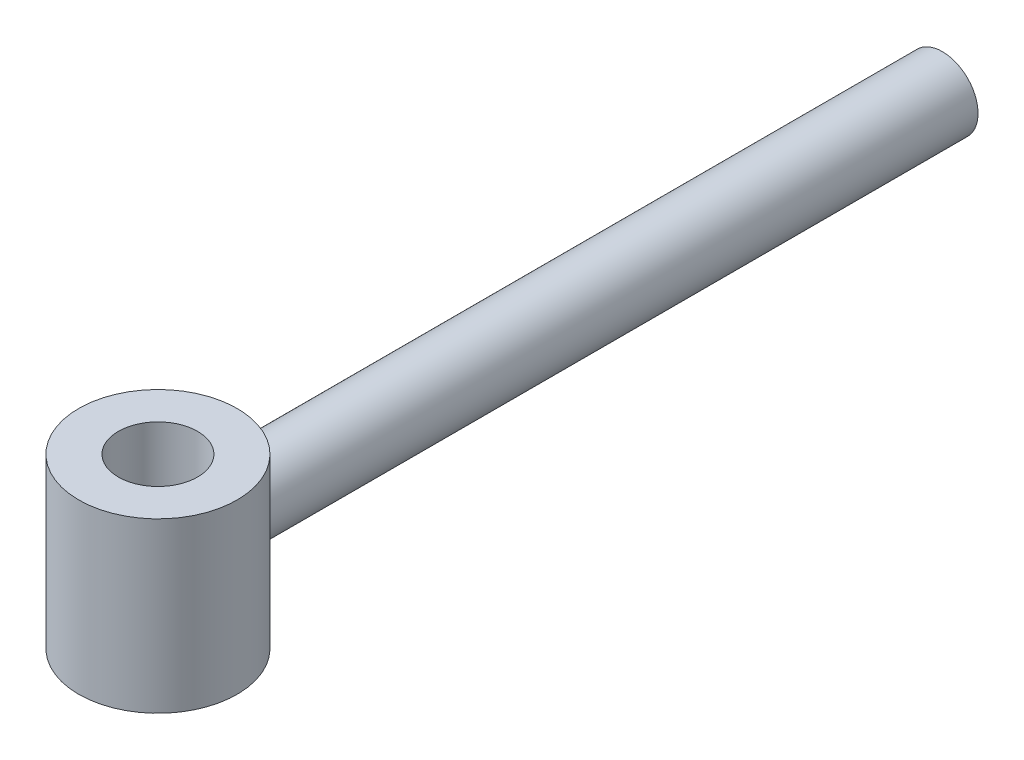
from build123d import *

# Parameters (mm, degrees)
SKETCH1_R                = 40
SKETCH1_R_2              = 20
BOSS_EXTRUDE1_DEPTH      = 80
BOSS_EXTRUDE1_DEPTH_BACK = 5
SKETCH2_R                = 18
BOSS_EXTRUDE2_DEPTH      = 356
BOSS_EXTRUDE2_DEPTH_BACK = 13


with BuildPart() as part:
    # Sketch1 → Boss-Extrude1 (new body, two sides)
    with BuildSketch(Plane(origin=(0, 0, 0), x_dir=(1, 0, 0), z_dir=(0, 1, 0))) as boss_extrude1_sk:
        Circle(SKETCH1_R)
        Circle(SKETCH1_R_2, mode=Mode.SUBTRACT)
    extrude(amount=BOSS_EXTRUDE1_DEPTH)
    extrude(boss_extrude1_sk.sketch, amount=-BOSS_EXTRUDE1_DEPTH_BACK)


with BuildPart() as body_2:
    # Sketch2 → Boss-Extrude2 (new body, two sides)
    with BuildSketch(Plane(origin=(0, 0, -40), x_dir=(-1, 0, 0), z_dir=(0, 0, -1))) as boss_extrude2_sk:
        with Locations((0, 40)):
            Circle(SKETCH2_R)
    extrude(amount=BOSS_EXTRUDE2_DEPTH)
    extrude(boss_extrude2_sk.sketch, amount=-BOSS_EXTRUDE2_DEPTH_BACK)


solid = Compound([part.part, body_2.part])
